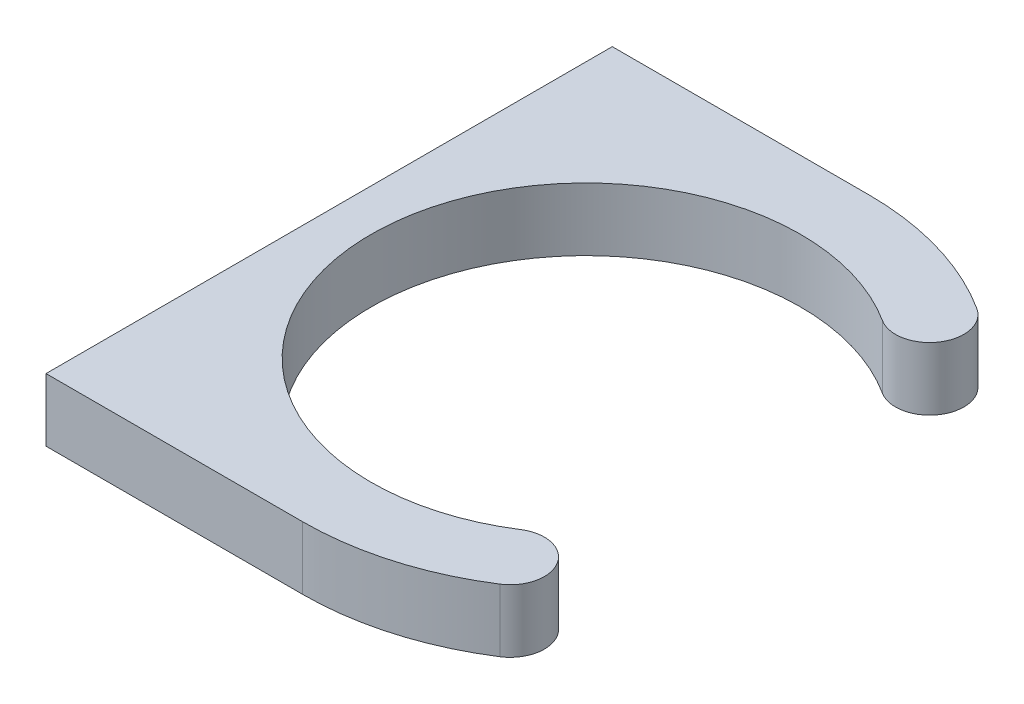
from build123d import *

# Parameters (mm, degrees)
BOSS_EXTRUDE1_DEPTH = 4.7625
SKETCH2_R           = 1.3890625
CUT_EXTRUDE1_DEPTH  = 25.4


with BuildPart() as part:
    # Sketch1 → Boss-Extrude1 (new body, symmetric)
    with BuildSketch(Plane(origin=(0, 0, 0), x_dir=(1, 0, 0), z_dir=(0, 1, 0))):
        with BuildLine():
            Line((-38.862, 42.8625), (-38.862, -42.8625))
            Line((-38.862, -42.8625), (0, -42.8625))
            ThreePointArc((0, -42.8625), (12.029787175, -41.139739022), (23.092554324, -36.109941028))
            ThreePointArc((23.092554324, -36.109941028), (24.664283237, -28.961787885), (17.516130095, -27.390058972))
            ThreePointArc((17.516130095, -27.390058972), (-32.512, 0), (17.516130095, 27.390058972))
            ThreePointArc((17.516130095, 27.390058972), (24.664283237, 28.961787885), (23.092554324, 36.109941028))
            ThreePointArc((23.092554324, 36.109941028), (12.029787175, 41.139739022), (0, 42.8625))
            Line((0, 42.8625), (-38.862, 42.8625))
        make_face()
    extrude(amount=BOSS_EXTRUDE1_DEPTH, both=True)

    # Sketch2 → Cut-Extrude1 (cut)
    with BuildSketch(Plane.ZY.offset(38.862)):
        with Locations((-38.1, 0)):
            Circle(SKETCH2_R)
        with Locations((38.1, 0)):
            Circle(SKETCH2_R)
    extrude(amount=-CUT_EXTRUDE1_DEPTH, mode=Mode.SUBTRACT)


solid = part.part
